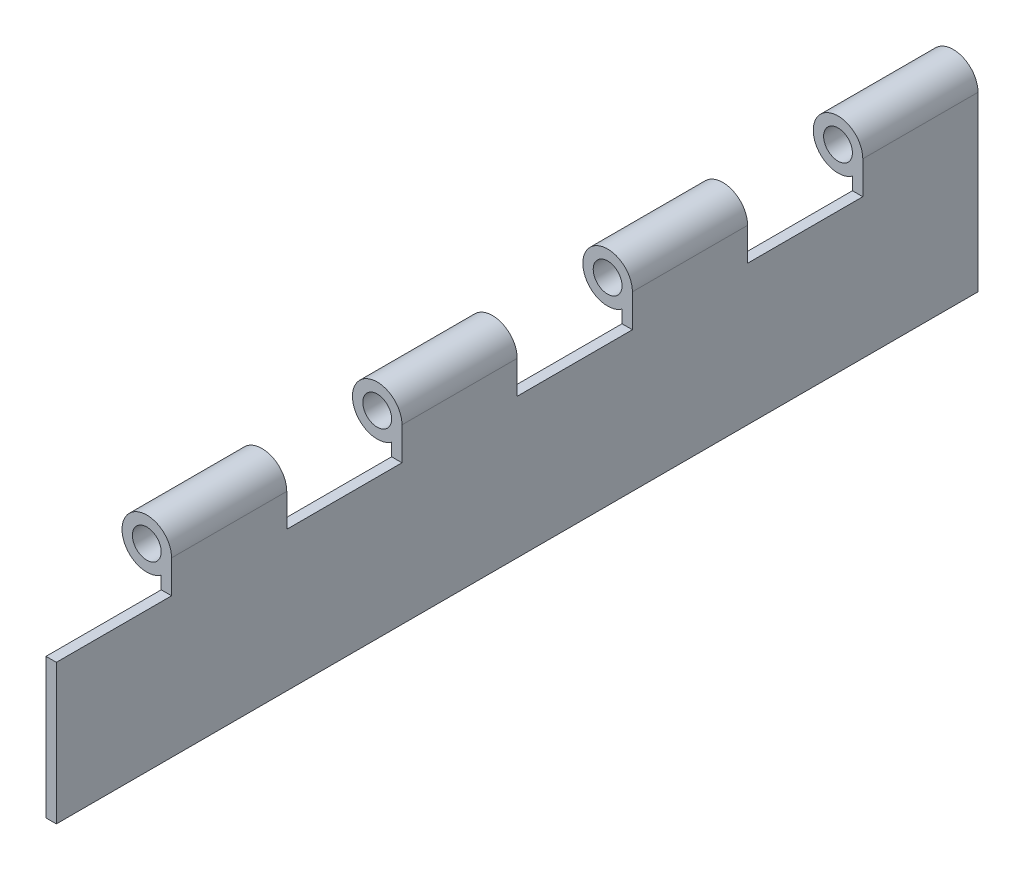
from build123d import *

# Parameters (mm, degrees)
SKETCH1_R           = 3.175
BOSS_EXTRUDE1_DEPTH = 203.2
SKETCH2_W           = 25.4
SKETCH2_H           = 12.7
CUT_EXTRUDE1_DEPTH  = 11.922
LPATTERN1_COUNT     = 4
LPATTERN1_PITCH     = 50.8


with BuildPart() as part:
    # Sketch1 → Boss-Extrude1 (new body)
    with BuildSketch(Plane.XY):
        with BuildLine():
            Line((5.461, 0), (5.461, -38.1))
            Line((5.461, -38.1), (3.175, -38.1))
            Line((3.175, -38.1), (3.175, -4.443185344))
            ThreePointArc((3.175, -4.443185344), (-4.855985791, 2.498384078), (5.461, 0))
        make_face()
        Circle(SKETCH1_R, mode=Mode.SUBTRACT)
    extrude(amount=BOSS_EXTRUDE1_DEPTH)

    # Sketch2 → Cut-Extrude1 (cut, through all)
    with BuildSketch(Plane(origin=(5.461, 0, 0), x_dir=(0, 0, -1), z_dir=(1, 0, 0))):
        with Locations((-190.5, -0.889)):
            Rectangle(SKETCH2_W, SKETCH2_H)
    cut_extrude1 = extrude(amount=-CUT_EXTRUDE1_DEPTH, mode=Mode.SUBTRACT)

    # LPattern1: Cut-Extrude1 ×4
    with Locations(*[(0, 0, -i * LPATTERN1_PITCH) for i in range(1, LPATTERN1_COUNT)]):
        add(cut_extrude1, mode=Mode.SUBTRACT)


solid = part.part
